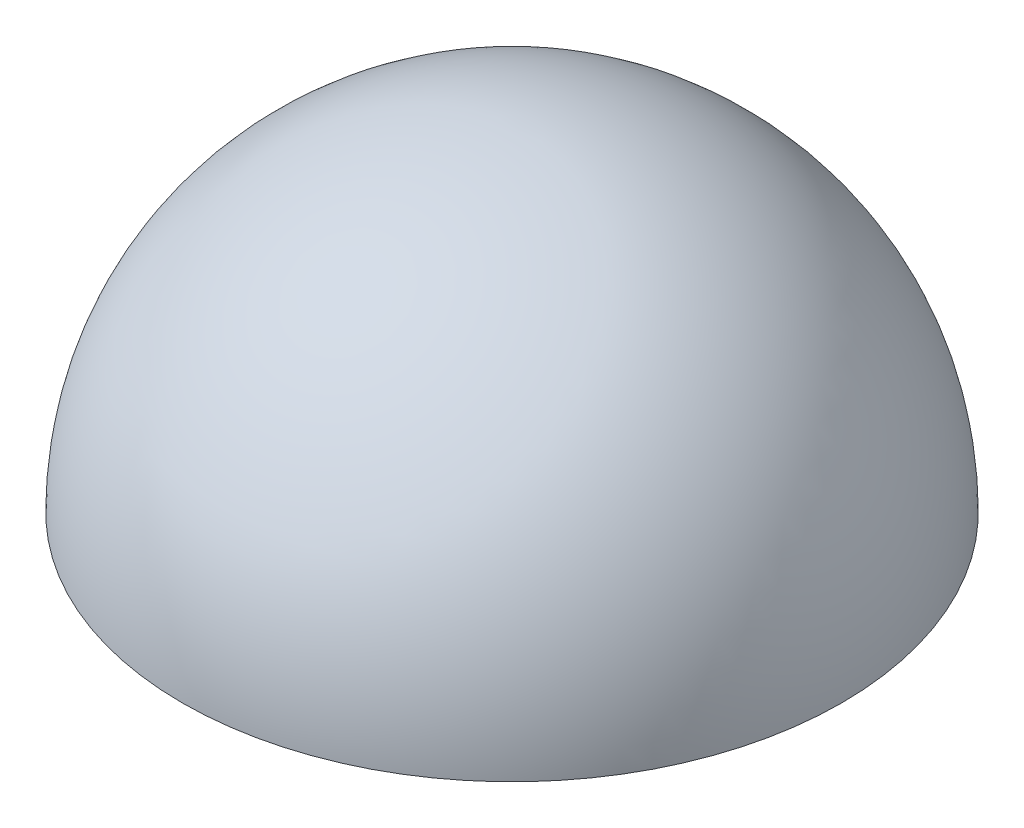
from build123d import *


with BuildPart() as part:
    # Esquisse1 → Révolution1 (revolve)
    with BuildSketch(Plane.XY):
        with BuildLine():
            Line((0, 72), (0, 77))
            ThreePointArc((0, 77), (54.447222151, 54.447222151), (77, 0))
            Line((77, 0), (72, 0))
            ThreePointArc((72, 0), (50.911688245, 50.911688245), (0, 72))
        make_face()
    revolve(axis=Axis((0, 0, 0), (0, 1, 0)))


solid = part.part
